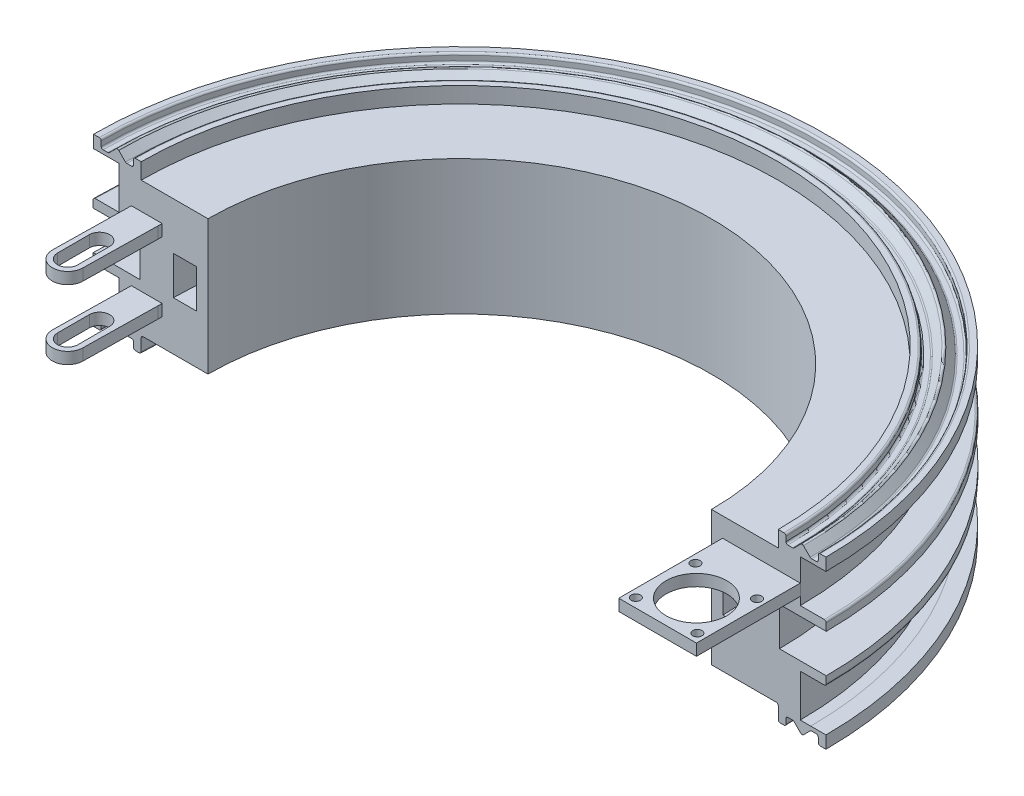
from build123d import *

# Parameters (mm, degrees)
SKETCH1_W           = 6
SKETCH1_H           = 10
FILLET1_R           = 0.5
FILLET2_R           = 0.5
FILLET3_R           = 0.5
FILLET4_R           = 0.5
FILLET5_R           = 0.5
FILLET6_R           = 0.5
FILLET7_R           = 0.5
FILLET9_R           = 0.5
FILLET10_R          = 0.5
SKETCH13_W          = 8
SKETCH13_H          = 3
BOSS_EXTRUDE6_DEPTH = 1
BOSS_EXTRUDE7_DEPTH = 3
SKETCH17_W          = 20.2
SKETCH17_H          = 3
BOSS_EXTRUDE8_DEPTH = 27
SKETCH21_R          = 7.9
SKETCH21_R_2        = 1.2
CUT_EXTRUDE3_DEPTH  = 22.2


with BuildPart() as part:
    # Sweep3: sweep along a path in Sketch3
    with BuildLine(Plane(origin=(0, 0, 0), x_dir=(1, 0, 0), z_dir=(0, 1, 0))) as sweep3_path:
        ThreePointArc((0, 0), (65.459977148, 65.459977148), (130.919954296, 0))
    # Sketch1 → Sweep3 (sweep)
    with BuildSketch(Plane.XY):
        Polygon((0, 21.243112223), (0, -13.756887777), (-17.368376618, -13.756887777), (-17.368376618, -17.916258724), (-19.368376618, -17.916258724), (-19.368376618, -15.656355089), (-21.318376618, -15.656355089), (-23.568376618, -17.906355089), (-25.818376618, -15.656355089), (-27.768376618, -15.656355089), (-27.768376618, -17.900013904), (-29.768376618, -17.900013904), (-29.768376618, -14.656355089), (-25.818376618, -14.656355089), (-23.090911996, -14.656355089), (-23.090911996, -3.637682855), (-29.846967972, -3.637682855), (-29.846967972, -1.30053875), (-17.670858196, -1.30053875), (-17.670858196, 8.69946125), (-29.846967972, 8.69946125), (-29.846967972, 11.1239073), (-23.090911996, 11.1239073), (-23.090911996, 22.142579535), (-25.818376618, 22.142579535), (-29.768376618, 22.142579535), (-29.768376618, 25.386238349), (-27.768376618, 25.386238349), (-27.768376618, 23.142579535), (-25.818376618, 23.142579535), (-23.568376618, 25.392579535), (-21.318376618, 23.142579535), (-19.368376618, 23.142579535), (-19.368376618, 25.402483169), (-17.368376618, 25.402483169), (-17.368376618, 21.243112223), align=None)
        with Locations((-6, 3.950784343)):
            Rectangle(SKETCH1_W, SKETCH1_H, mode=Mode.SUBTRACT)
    sweep(path=sweep3_path.line)

    # Fillet1
    fillet1_edges = [part.edges().sort_by_distance(p)[0] for p in [
        (65.459977148, 25.392579535, -89.028353766),
    ]]
    fillet(fillet1_edges, radius=FILLET1_R)

    # Fillet2
    fillet2_edges = [part.edges().sort_by_distance(p)[0] for p in [
        (65.459977148, 23.142579535, -91.278353766),
    ]]
    fillet(fillet2_edges, radius=FILLET2_R)

    # Fillet3
    fillet3_edges = [part.edges().sort_by_distance(p)[0] for p in [
        (65.459977148, 23.142579535, -93.228353766),
    ]]
    fillet(fillet3_edges, radius=FILLET3_R)

    # Fillet4
    fillet4_edges = [part.edges().sort_by_distance(p)[0] for p in [
        (65.459977148, 23.142579535, -86.778353766),
        (65.459977148, 23.142579535, -84.828353766),
    ]]
    fillet(fillet4_edges, radius=FILLET4_R)

    # Fillet5
    fillet5_edges = [part.edges().sort_by_distance(p)[0] for p in [
        (65.459977148, -17.916258724, -84.828353766),
        (65.459977148, -15.656355089, -86.778353766),
        (65.459977148, -17.906355089, -89.028353766),
    ]]
    fillet(fillet5_edges, radius=FILLET5_R)

    # Fillet6
    fillet6_edges = [part.edges().sort_by_distance(p)[0] for p in [
        (65.459977148, -13.756887777, -82.828353766),
        (65.459977148, -17.916258724, -82.828353766),
        (65.459977148, -15.656355089, -84.828353766),
    ]]
    fillet(fillet6_edges, radius=FILLET6_R)

    # Fillet7
    fillet7_edges = [part.edges().sort_by_distance(p)[0] for p in [
        (65.459977148, -15.656355089, -91.278353766),
        (65.459977148, -15.656355089, -93.228353766),
        (65.459977148, -17.900013904, -93.228353766),
    ]]
    fillet(fillet7_edges, radius=FILLET7_R)

    # Fillet9
    fillet9_edges = [part.edges().sort_by_distance(p)[0] for p in [
        (65.459977148, -3.637682855, -95.30694512),
        (65.459977148, 11.1239073, -95.30694512),
    ]]
    fillet(fillet9_edges, radius=FILLET9_R)

    # Fillet10
    fillet10_edges = [part.edges().sort_by_distance(p)[0] for p in [
        (65.459977148, 25.386238349, -93.228353766),
        (65.459977148, 25.402483169, -84.828353766),
    ]]
    fillet(fillet10_edges, radius=FILLET10_R)

    # Sketch13 → Boss-Extrude6 (add)
    with BuildSketch(Plane.XY):
        with Locations((-15.938702062, -5.30053875)):
            Rectangle(SKETCH13_W, SKETCH13_H)
        with Locations((-15.938702062, 12.69946125)):
            Rectangle(SKETCH13_W, SKETCH13_H)
    boss_extrude6 = extrude(amount=BOSS_EXTRUDE6_DEPTH)

    # Sketch19 → Boss-Extrude7 (add)
    with BuildSketch(Plane(origin=(0, 14.19946125, 0), x_dir=(1, 0, 0), z_dir=(0, 1, 0))):
        with BuildLine():
            Line((-11.938702062, -1), (-19.938702062, -1))
            Line((-19.938702062, -1), (-20.241078798, -20.23652739))
            ThreePointArc((-20.241078798, -20.23652739), (-16.241078798, -24.23652739), (-12.241078798, -20.23652739))
            Line((-12.241078798, -20.23652739), (-11.938702062, -1))
        make_face()
        with BuildLine():
            Line((-13.591078798, -11.973039646), (-13.591078798, -20.23652739))
            ThreePointArc((-13.591078798, -20.23652739), (-16.241078798, -22.88652739), (-18.891078798, -20.23652739))
            Line((-18.891078798, -20.23652739), (-18.891078798, -11.973039646))
            ThreePointArc((-18.891078798, -11.973039646), (-16.241078798, -9.323039646), (-13.591078798, -11.973039646))
        make_face(mode=Mode.SUBTRACT)
    boss_extrude7 = extrude(amount=-BOSS_EXTRUDE7_DEPTH)

    # Mirror1: Boss-Extrude6, Boss-Extrude7 across plane
    add(boss_extrude6.mirror(Plane.ZX.offset(3.69946125)))
    add(boss_extrude7.mirror(Plane.ZX.offset(3.69946125)))

    # Sketch17 → Boss-Extrude8 (add)
    with BuildSketch(Plane.XY):
        with Locations((143.910866292, 14.693112223)):
            Rectangle(SKETCH17_W, SKETCH17_H)
    extrude(amount=BOSS_EXTRUDE8_DEPTH)

    # Sketch21 → Cut-Extrude3 (cut)
    with BuildSketch(Plane.XZ.offset(-13.193112223)):
        with Locations(Location((143.910866292, 16.9, 0), (0, 0, 270))):
            Circle(SKETCH21_R)
        with Locations(Location((135.908547878, 24.65, 0), (0, 0, 270))):
            Circle(SKETCH21_R_2)
        with Locations((135.908547878, 9.15)):
            Circle(SKETCH21_R_2)
        with Locations(Location((151.913184706, 9.15, 0), (0, 0, 270))):
            Circle(SKETCH21_R_2)
        with Locations((151.913184706, 24.65)):
            Circle(SKETCH21_R_2)
    extrude(amount=-CUT_EXTRUDE3_DEPTH, mode=Mode.SUBTRACT)


solid = part.part
